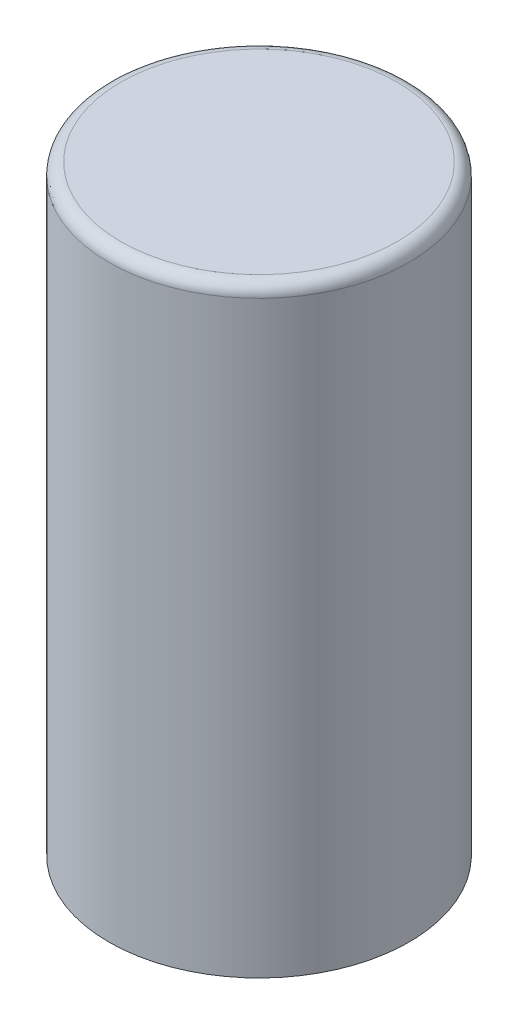
from build123d import *

# Parameters (mm, degrees)
SKETCH1_R           = 6.25
BOSS_EXTRUDE1_DEPTH = 25
FILLET1_R           = 0.5


with BuildPart() as part:
    # Sketch1 → Boss-Extrude1 (new body)
    with BuildSketch(Plane(origin=(0, 0, 0), x_dir=(1, 0, 0), z_dir=(0, 1, 0))):
        Circle(SKETCH1_R)
    extrude(amount=BOSS_EXTRUDE1_DEPTH)

    # Fillet1
    fillet1_edges = [part.edges().sort_by_distance(p)[0] for p in [
        (-6.25, 25, 0),
    ]]
    fillet(fillet1_edges, radius=FILLET1_R)


solid = part.part
